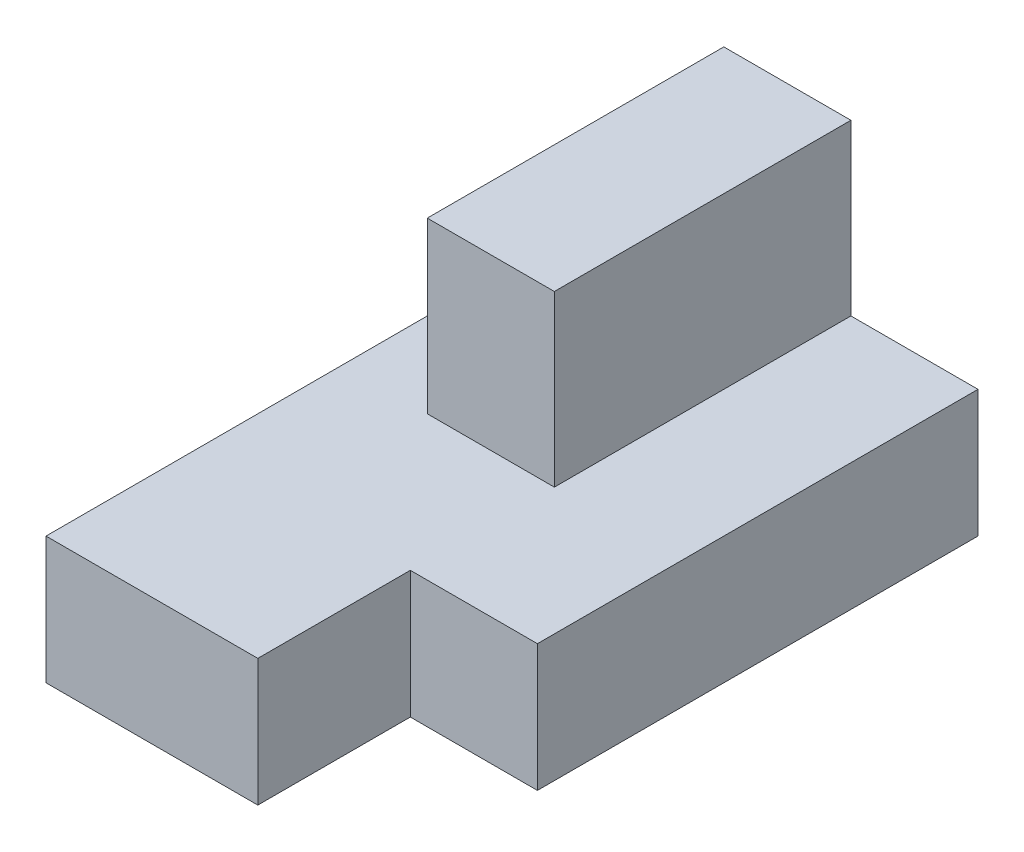
from build123d import *

# Parameters (mm, degrees)
Y_KSEKLIK_EKSTR_ZYON1_DEPTH = 15
IZIM2_W                     = 15
IZIM2_H                     = 35
Y_KSEKLIK_EKSTR_ZYON2_DEPTH = 20


with BuildPart() as part:
    # Çizim1 → Yükseklik-Ekstrüzyon1 (new body)
    with BuildSketch(Plane(origin=(0, 0, 0), x_dir=(1, 0, 0), z_dir=(0, 1, 0))):
        Polygon((5, -35), (5, -17), (20, -17), (20, 35), (-20, 35), (-20, -35), align=None)
    extrude(amount=Y_KSEKLIK_EKSTR_ZYON1_DEPTH)

    # Çizim2 → Yükseklik-Ekstrüzyon2 (add)
    with BuildSketch(Plane(origin=(0, 15, 0), x_dir=(1, 0, 0), z_dir=(0, 1, 0))):
        with Locations((-2.5, 17.5)):
            Rectangle(IZIM2_W, IZIM2_H)
    extrude(amount=Y_KSEKLIK_EKSTR_ZYON2_DEPTH)


solid = part.part
